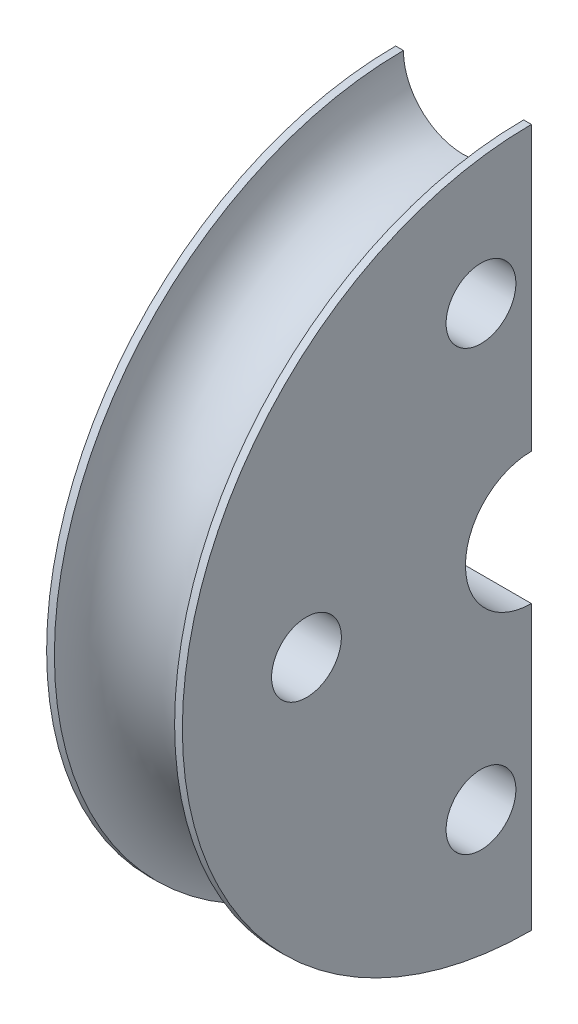
from build123d import *

# Parameters (mm, degrees)
R_VOLUTION1_ANGLE       = 180
ESQUISSE2_R             = 9
ENL_V_MAT_EXTRU_1_DEPTH = 36


with BuildPart() as part:
    # Esquisse1 → Révolution1 (revolve)
    with BuildSketch(Plane.XY):
        with BuildLine():
            Line((0, 17), (0, 90))
            Line((0, 90), (2, 90))
            ThreePointArc((2, 90), (17.5, 74.5), (33, 90))
            Line((33, 90), (35, 90))
            Line((35, 90), (35, 17))
            Line((35, 17), (0, 17))
        make_face()
    revolve(axis=Axis((0, 0, 0), (1, 0, 0)), revolution_arc=R_VOLUTION1_ANGLE)

    # Esquisse2 → Enlèv. mat.-Extru.1 (cut, through all)
    with BuildSketch(Plane.ZY):
        with Locations((13, -56.524331044)):
            Circle(ESQUISSE2_R)
        with Locations((58, 0)):
            Circle(ESQUISSE2_R)
        with Locations((13, 56.524331044)):
            Circle(ESQUISSE2_R)
    extrude(amount=-ENL_V_MAT_EXTRU_1_DEPTH, mode=Mode.SUBTRACT)


solid = part.part
